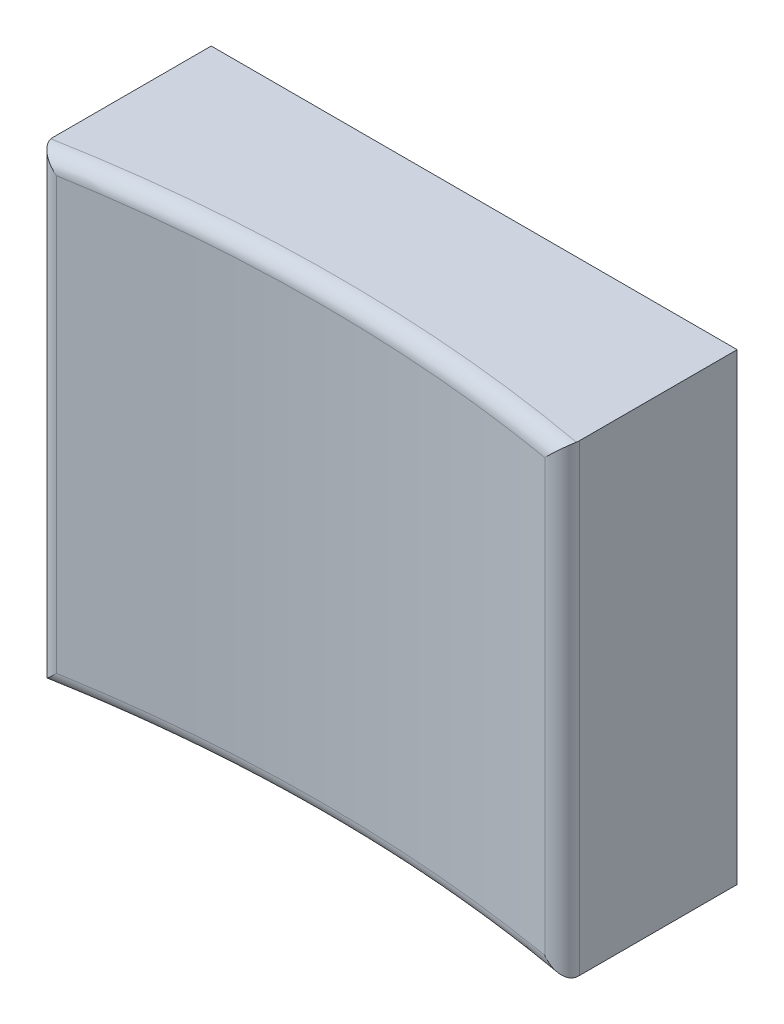
from build123d import *

# Parameters (mm, degrees)
SKETCH1_W      = 8.3058
SKETCH1_H      = 7.3152
KEY_DEPTH      = 2.794
EXTRUDE2_DEPTH = 8.3152
FILLET1_R      = 0.254


with BuildPart() as part:
    # Sketch1 → key (new body)
    with BuildSketch(Plane.XY):
        Rectangle(SKETCH1_W, SKETCH1_H)
    extrude(amount=KEY_DEPTH)

    # Sketch2 → Extrude2 (cut, through all)
    with BuildSketch(Plane.XZ.offset(3.6576)):
        with BuildLine():
            ThreePointArc((-4.1529, 2.794), (0, 2.413613466), (4.1529, 2.794))
            Line((4.1529, 2.794), (-4.1529, 2.794))
        make_face()
    extrude(amount=-EXTRUDE2_DEPTH, mode=Mode.SUBTRACT)

    # Fillet1
    fillet1_edges = [part.edges().sort_by_distance(p)[0] for p in [
        (4.1529, 0, 2.794),
        (0, 3.6576, 2.413613466),
        (0, -3.6576, 2.413613466),
        (-4.1529, 0, 2.794),
    ]]
    fillet(fillet1_edges, radius=FILLET1_R)


solid = part.part
